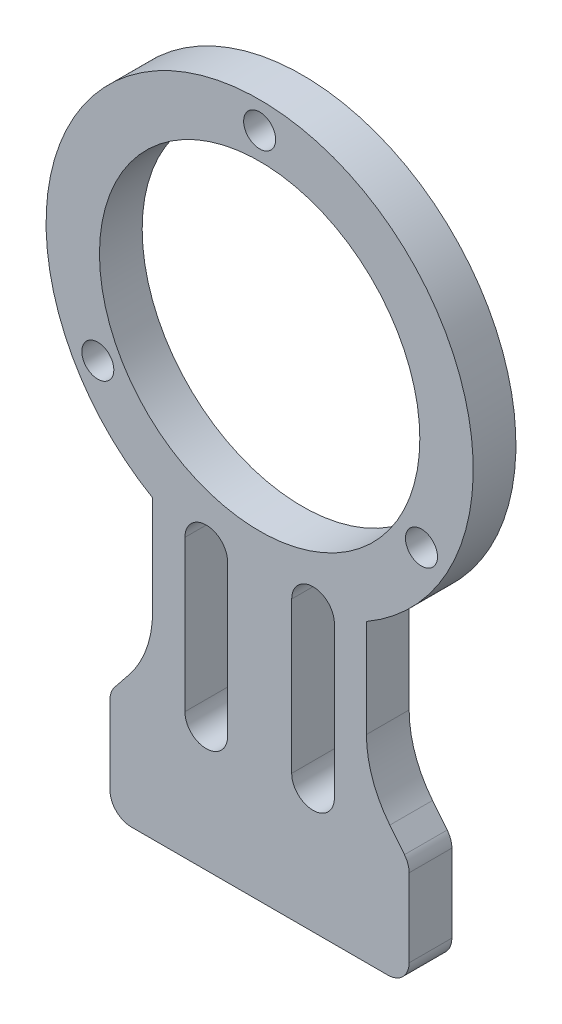
from build123d import *

# Parameters (mm, degrees)
SKETCH1_R           = 15
SKETCH1_R_2         = 1.5
BOSS_EXTRUDE1_DEPTH = 4
SKETCH2_R           = 1
CUT_EXTRUDE1_DEPTH  = 4


with BuildPart() as part:
    # Sketch1 → Boss-Extrude1 (new body)
    with BuildSketch(Plane.XY):
        with BuildLine():
            Line((12.191311906, -32.739139882), (13.561737619, -34.452172024))
            ThreePointArc((13.561737619, -34.452172024), (13.887256638, -35.039548236), (14, -35.701562119))
            Line((14, -35.701562119), (14, -43))
            ThreePointArc((14, -43), (13.414213562, -44.414213562), (12, -45))
            Line((12, -45), (-12.018212743, -45))
            ThreePointArc((-12.018212743, -45), (-13.432426305, -44.414213562), (-14.018212743, -43))
            Line((-14.018212743, -43), (-14.018212743, -35.691034212))
            ThreePointArc((-14.018212743, -35.691034212), (-13.905469381, -35.029020329), (-13.579950362, -34.441644117))
            Line((-13.579950362, -34.441644117), (-12.209524648, -32.728611975))
            ThreePointArc((-12.209524648, -32.728611975), (-10.581929551, -29.791730914), (-10.018212743, -26.481661499))
            Line((-10.018212743, -26.481661499), (-10.018212743, -17.309980169))
            ThreePointArc((-10.018212743, -17.309980169), (0.010518327, 19.999997234), (10, -17.320508076))
            Line((10, -17.320508076), (10, -26.492189406))
            ThreePointArc((10, -26.492189406), (10.563716808, -29.802258821), (12.191311906, -32.739139882))
        make_face()
        Circle(SKETCH1_R, mode=Mode.SUBTRACT)
        with Locations((0, 17.5)):
            Circle(SKETCH1_R_2, mode=Mode.SUBTRACT)
        with Locations((15.155444566, -8.75)):
            Circle(SKETCH1_R_2, mode=Mode.SUBTRACT)
        with Locations((-15.155444566, -8.75)):
            Circle(SKETCH1_R_2, mode=Mode.SUBTRACT)
        with BuildLine():
            Line((-3, -19), (-3, -33.13932584))
            ThreePointArc((-3, -33.13932584), (-5, -35.13932584), (-7, -33.13932584))
            Line((-7, -33.13932584), (-7, -19))
            ThreePointArc((-7, -19), (-5, -17), (-3, -19))
        make_face(mode=Mode.SUBTRACT)
        with BuildLine():
            Line((3, -19), (3, -33.13932584))
            ThreePointArc((3, -33.13932584), (5, -35.13932584), (7, -33.13932584))
            Line((7, -33.13932584), (7, -19))
            ThreePointArc((7, -19), (5, -17), (3, -19))
        make_face(mode=Mode.SUBTRACT)
    extrude(amount=BOSS_EXTRUDE1_DEPTH)

    # Sketch2 → Cut-Extrude1 (cut)
    with BuildSketch(Plane.XZ.offset(45)):
        with Locations((-10.009106371, 2)):
            Circle(SKETCH2_R)
        with Locations((9.990893629, 2)):
            Circle(SKETCH2_R)
    extrude(amount=-CUT_EXTRUDE1_DEPTH, mode=Mode.SUBTRACT)


solid = part.part
